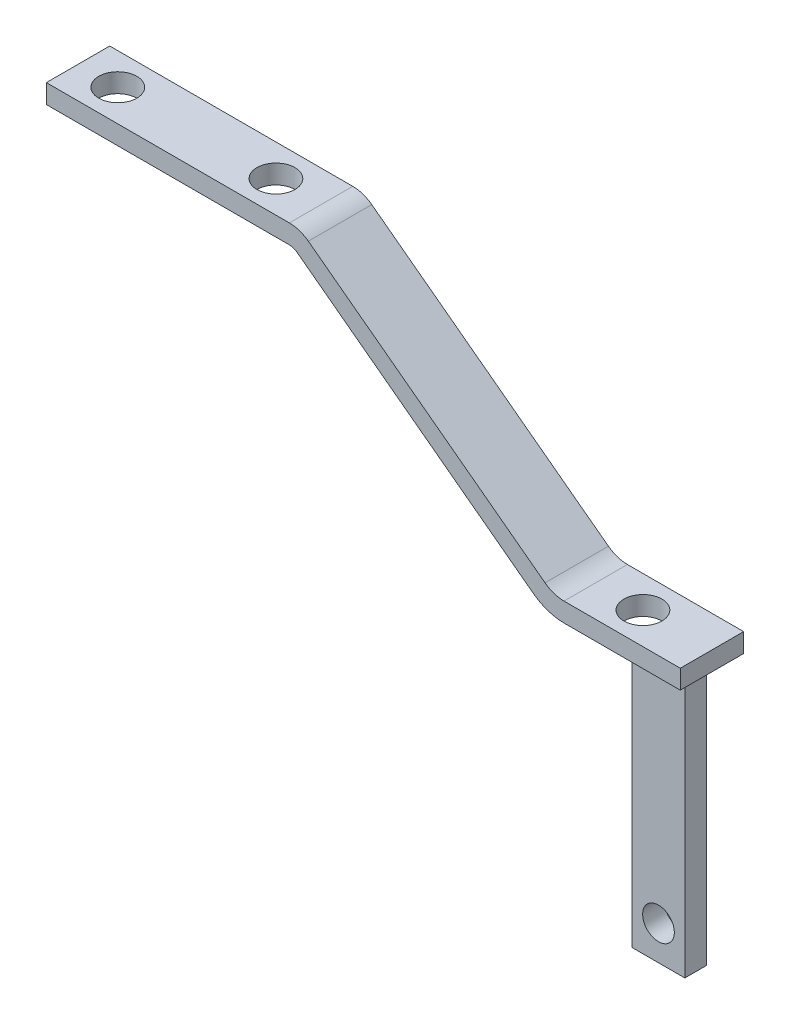
from build123d import *

# Parameters (mm, degrees)
BOSS_EXTRUDE1_DEPTH = 10
SKETCH2_R           = 3
CUT_EXTRUDE1_DEPTH  = 34
SKETCH3_W           = 8.31174776
SKETCH3_H           = 3.43251071
BOSS_EXTRUDE2_DEPTH = 40
SKETCH4_R           = 2.5
CUT_EXTRUDE2_DEPTH  = 9.963348995


with BuildPart() as part:
    # Sketch1 → Boss-Extrude1 (new body)
    with BuildSketch(Plane.XY):
        with BuildLine():
            Line((0, 0), (38.333333333, 0))
            ThreePointArc((38.333333333, 0), (39.914472163, -0.25658351), (41.333333333, -1))
            Line((41.333333333, -1), (78.666666667, -29))
            ThreePointArc((78.666666667, -29), (80.085527837, -29.74341649), (81.666666667, -30))
            Line((81.666666667, -30), (100, -30))
            Line((100, -30), (100, -33))
            Line((100, -33), (81.666666667, -33))
            ThreePointArc((81.666666667, -33), (79.136844539, -32.589466384), (76.866666667, -31.4))
            Line((76.866666667, -31.4), (39.533333333, -3.4))
            ThreePointArc((39.533333333, -3.4), (38.965788865, -3.102633404), (38.333333333, -3))
            Line((38.333333333, -3), (0, -3))
            Line((0, -3), (0, 0))
        make_face()
    extrude(amount=BOSS_EXTRUDE1_DEPTH)

    # Sketch2 → Cut-Extrude1 (cut, through all)
    with BuildSketch(Plane(origin=(0, 0, 0), x_dir=(1, 0, 0), z_dir=(0, 1, 0))):
        with Locations((6.267592097, -5)):
            Circle(SKETCH2_R)
        with Locations((31.216017877, -5)):
            Circle(SKETCH2_R)
        with Locations((89.111430709, -5)):
            Circle(SKETCH2_R)
    extrude(amount=-CUT_EXTRUDE1_DEPTH, mode=Mode.SUBTRACT)

    # Sketch3 → Boss-Extrude2 (add)
    with BuildSketch(Plane.XZ.offset(33)):
        with Locations((95.527410175, 7.24709364)):
            Rectangle(SKETCH3_W, SKETCH3_H)
    extrude(amount=BOSS_EXTRUDE2_DEPTH)

    # Sketch4 → Cut-Extrude2 (cut, through all)
    with BuildSketch(Plane.XY.offset(8.963348995)):
        with Locations((95.527410175, -67.614542538)):
            Circle(SKETCH4_R)
    extrude(amount=-CUT_EXTRUDE2_DEPTH, mode=Mode.SUBTRACT)


solid = part.part
